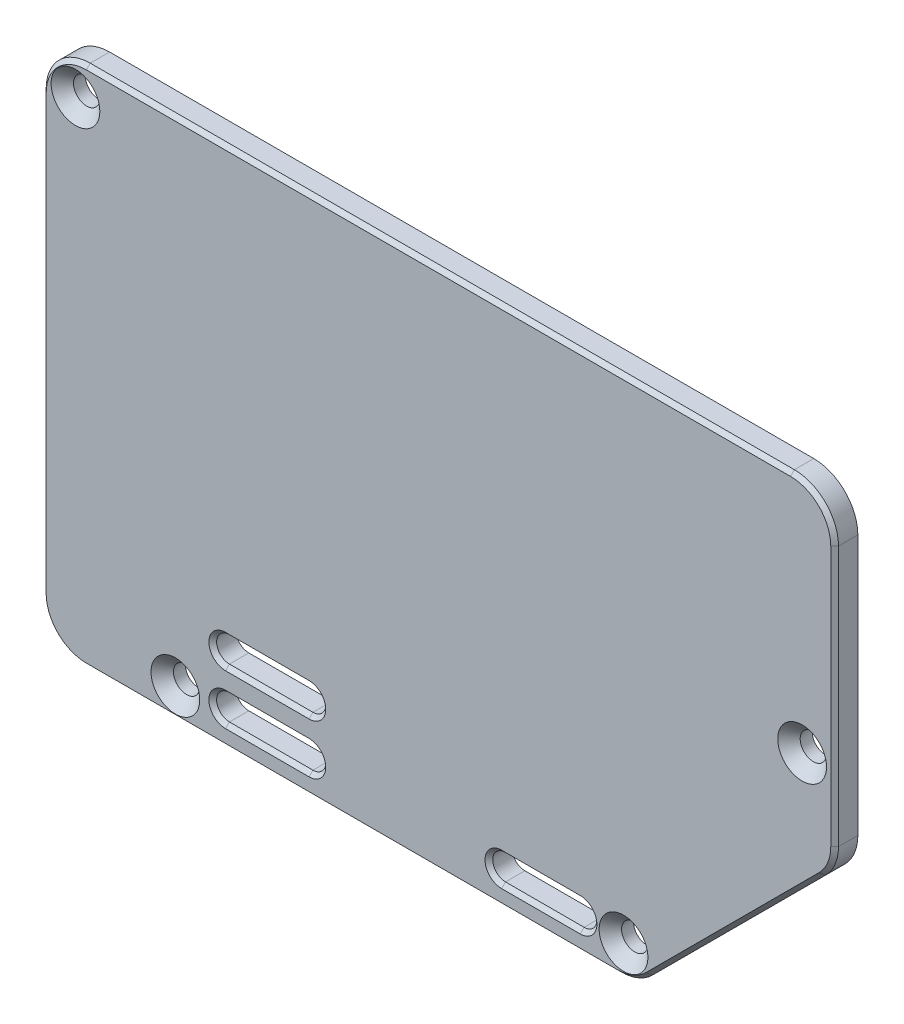
from build123d import *

# Parameters (mm, degrees)
BOSS_EXTRUDE1_DEPTH                            = 3
CSK_FOR_M3_FLAT_HEAD_MACHINE_SCREW1_AT_2_COUNT = 2
CSK_FOR_M3_FLAT_HEAD_MACHINE_SCREW1_AT_2_PITCH = 60.801526997
CSK_FOR_M3_FLAT_HEAD_MACHINE_SCREW1_AT_3_COUNT = 2
CSK_FOR_M3_FLAT_HEAD_MACHINE_SCREW1_AT_3_PITCH = 92.34886737
CSK_FOR_M3_FLAT_HEAD_MACHINE_SCREW1_AT_4_COUNT = 2
CSK_FOR_M3_FLAT_HEAD_MACHINE_SCREW1_AT_4_PITCH = 97.558137473
CUT_EXTRUDE1_DEPTH                             = 4
CHAMFER1_SIZE                                  = 0.5


with BuildPart() as part:
    # Sketch2 → Boss-Extrude1 (new body)
    with BuildSketch(Plane.XY.offset(8.62)):
        with BuildLine():
            Line((4.5, 66.2), (95.5, 66.2))
            ThreePointArc((95.5, 66.2), (99.530508653, 64.530508653), (101.2, 60.5))
            Line((101.2, 60.5), (101.2, 26.863961031))
            ThreePointArc((101.2, 26.863961031), (100.766113335, 24.682665466), (99.530508653, 22.833452378))
            Line((99.530508653, 22.833452378), (77.166547622, 0.469491347))
            ThreePointArc((77.166547622, 0.469491347), (75.317334534, -0.766113335), (73.136038969, -1.2))
            Line((73.136038969, -1.2), (4.5, -1.2))
            ThreePointArc((4.5, -1.2), (0.469491347, 0.469491347), (-1.2, 4.5))
            Line((-1.2, 4.5), (-1.2, 60.5))
            ThreePointArc((-1.2, 60.5), (0.469491347, 64.530508653), (4.5, 66.2))
        make_face()
    extrude(amount=BOSS_EXTRUDE1_DEPTH)

    # Sketch5 → CSK for M3 Flat Head Machine Screw1 (revolve, cut)
    with BuildSketch(Plane(origin=(3.085786438, 61.914213562, 11.62), x_dir=(0, -1, 0), z_dir=(1, 0, 0))):
        Polygon((0, 0), (0, 3), (1.7, 3), (1.7, 1.45), (3.15, 0), align=None)
    csk_for_m3_flat_head_machine_screw1 = revolve(axis=Axis((3.085786438, 61.914213562, 17.97), (0, 0, -1)), mode=Mode.SUBTRACT)

    # CSK for M3 Flat Head Machine Screw1 at 2: CSK for M3 Flat Head Machine Screw1 ×2
    with Locations(*[Vector(0.212399494, -0.977182918, 0) * (i * CSK_FOR_M3_FLAT_HEAD_MACHINE_SCREW1_AT_2_PITCH) for i in range(1, CSK_FOR_M3_FLAT_HEAD_MACHINE_SCREW1_AT_2_COUNT)]):
        add(csk_for_m3_flat_head_machine_screw1, mode=Mode.SUBTRACT)

    # CSK for M3 Flat Head Machine Screw1 at 3: CSK for M3 Flat Head Machine Screw1 ×2
    with Locations(*[Vector(0.767001446, -0.641645371, 0) * (i * CSK_FOR_M3_FLAT_HEAD_MACHINE_SCREW1_AT_3_PITCH) for i in range(1, CSK_FOR_M3_FLAT_HEAD_MACHINE_SCREW1_AT_3_COUNT)]):
        add(csk_for_m3_flat_head_machine_screw1, mode=Mode.SUBTRACT)

    # CSK for M3 Flat Head Machine Screw1 at 4: CSK for M3 Flat Head Machine Screw1 ×2
    with Locations(*[Vector(0.962648693, -0.270753565, 0) * (i * CSK_FOR_M3_FLAT_HEAD_MACHINE_SCREW1_AT_4_PITCH) for i in range(1, CSK_FOR_M3_FLAT_HEAD_MACHINE_SCREW1_AT_4_COUNT)]):
        add(csk_for_m3_flat_head_machine_screw1, mode=Mode.SUBTRACT)

    # Sketch6 → Cut-Extrude1 (cut, through all)
    with BuildSketch(Plane.XY.offset(11.62)):
        with BuildLine():
            Line((33.278, 7.9375), (22.483, 7.9375))
            ThreePointArc((22.483, 7.9375), (20.832, 9.5885), (22.483, 11.2395))
            Line((22.483, 11.2395), (33.278, 11.2395))
            ThreePointArc((33.278, 11.2395), (34.929, 9.5885), (33.278, 7.9375))
        make_face()
        with BuildLine():
            Line((33.278, 1.4605), (22.483, 1.4605))
            ThreePointArc((22.483, 1.4605), (20.832, 3.1115), (22.483, 4.7625))
            Line((22.483, 4.7625), (33.278, 4.7625))
            ThreePointArc((33.278, 4.7625), (34.929, 3.1115), (33.278, 1.4605))
        make_face()
        with BuildLine():
            Line((68.326, 1.397), (58.166, 1.397))
            ThreePointArc((58.166, 1.397), (56.515, 3.048), (58.166, 4.699))
            Line((58.166, 4.699), (68.326, 4.699))
            ThreePointArc((68.326, 4.699), (69.977, 3.048), (68.326, 1.397))
        make_face()
    extrude(amount=-CUT_EXTRUDE1_DEPTH, mode=Mode.SUBTRACT)

    # Chamfer1
    chamfer1_edges = [part.edges().sort_by_distance(p)[0] for p in [
        (75.317334534, -0.766113335, 11.62),
        (88.348528137, 11.651471863, 11.62),
        (100.766113335, 24.682665466, 11.62),
        (101.2, 43.681980515, 11.62),
        (99.530508653, 64.530508653, 11.62),
        (50, 66.2, 11.62),
        (0.469491347, 64.530508653, 11.62),
        (-1.2, 32.5, 11.62),
        (0.469491347, 0.469491347, 11.62),
        (34.929, 9.5885, 11.62),
        (27.8805, 11.2395, 11.62),
        (20.832, 9.5885, 11.62),
        (27.8805, 7.9375, 11.62),
        (38.818019485, -1.2, 11.62),
        (34.929, 3.1115, 11.62),
        (27.8805, 4.7625, 11.62),
        (20.832, 3.1115, 11.62),
        (27.8805, 1.4605, 11.62),
        (69.977, 3.048, 11.62),
        (63.246, 4.699, 11.62),
        (56.515, 3.048, 11.62),
        (63.246, 1.397, 11.62),
    ]]
    chamfer(chamfer1_edges, length=CHAMFER1_SIZE)


solid = part.part
